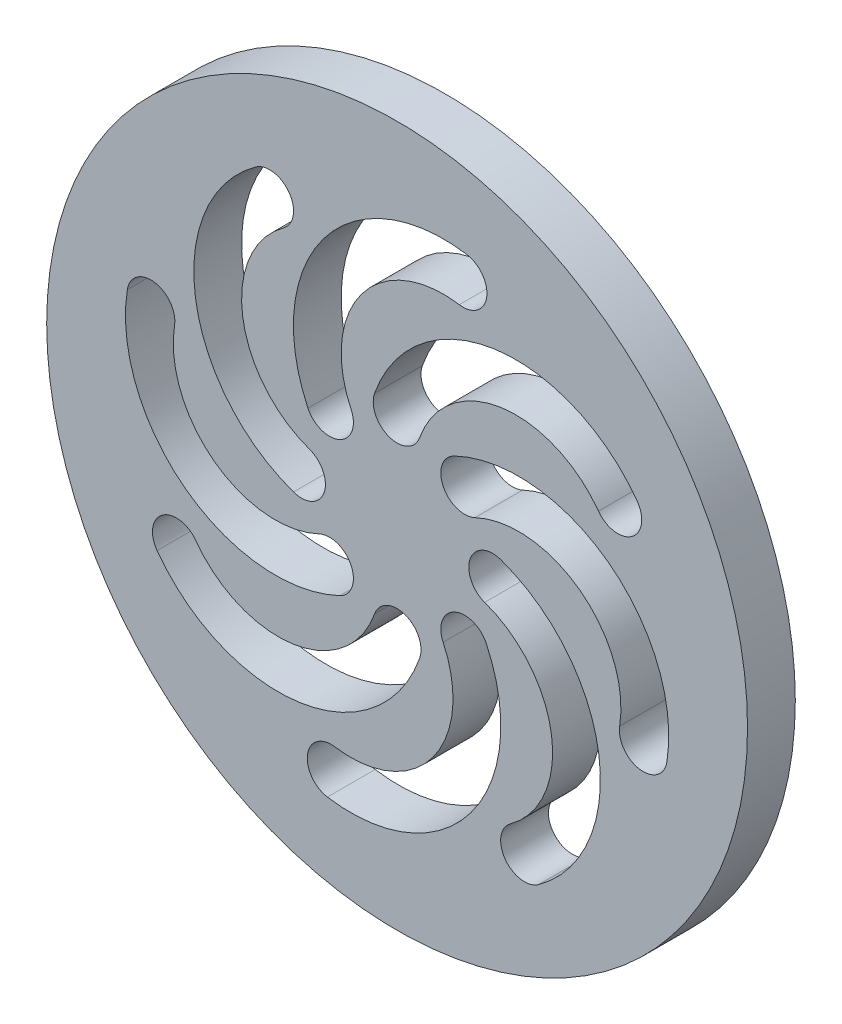
from build123d import *

# Parameters (mm, degrees)
SKETCH1_R           = 34.925
BOSS_EXTRUDE1_DEPTH = 4.7625


with BuildPart() as part:
    # Sketch1 → Boss-Extrude1 (new body)
    with BuildSketch(Plane.XY):
        Circle(SKETCH1_R)
        with BuildLine():
            ThreePointArc((2.243888697, 8.727933453), (-0.797066547, 7.281111303), (-2.243888697, 10.322066547))
            ThreePointArc((-2.243888697, 10.322066547), (9.70011878, 20.108105734), (23.923949148, 14.099068603))
            ThreePointArc((23.923949148, 14.099068603), (23.396113859, 10.773096108), (20.070141364, 11.300931397))
            ThreePointArc((20.070141364, 11.300931397), (10.380475923, 15.394453179), (2.243888697, 8.727933453))
        make_face(mode=Mode.SUBTRACT)
        with BuildLine():
            ThreePointArc((5.712134337, 8.885472165), (21.077597689, 7.359558154), (26.886333692, -6.947239658))
            ThreePointArc((26.886333692, -6.947239658), (24.161280075, -8.92582145), (22.182698283, -6.200767833))
            ThreePointArc((22.182698283, -6.200767833), (18.225627153, 3.545417318), (7.758249844, 4.584912017))
            ThreePointArc((7.758249844, 4.584912017), (4.584912017, 5.712134337), (5.712134337, 8.885472165))
        make_face(mode=Mode.SUBTRACT)
        with BuildLine():
            ThreePointArc((10.322066547, 2.243888697), (20.108105734, -9.70011878), (14.099068603, -23.923949148))
            ThreePointArc((14.099068603, -23.923949148), (10.773096108, -23.396113859), (11.300931397, -20.070141364))
            ThreePointArc((11.300931397, -20.070141364), (15.394453179, -10.380475923), (8.727933453, -2.243888697))
            ThreePointArc((8.727933453, -2.243888697), (7.281111303, 0.797066547), (10.322066547, 2.243888697))
        make_face(mode=Mode.SUBTRACT)
        with BuildLine():
            ThreePointArc((8.885472165, -5.712134337), (7.359558154, -21.077597689), (-6.947239658, -26.886333692))
            ThreePointArc((-6.947239658, -26.886333692), (-8.92582145, -24.161280075), (-6.200767833, -22.182698283))
            ThreePointArc((-6.200767833, -22.182698283), (3.545417318, -18.225627153), (4.584912017, -7.758249844))
            ThreePointArc((4.584912017, -7.758249844), (5.712134337, -4.584912017), (8.885472165, -5.712134337))
        make_face(mode=Mode.SUBTRACT)
        with BuildLine():
            ThreePointArc((2.243888697, -10.322066547), (-9.70011878, -20.108105734), (-23.923949148, -14.099068603))
            ThreePointArc((-23.923949148, -14.099068603), (-23.396113859, -10.773096108), (-20.070141364, -11.300931397))
            ThreePointArc((-20.070141364, -11.300931397), (-10.380475923, -15.394453179), (-2.243888697, -8.727933453))
            ThreePointArc((-2.243888697, -8.727933453), (0.797066547, -7.281111303), (2.243888697, -10.322066547))
        make_face(mode=Mode.SUBTRACT)
        with BuildLine():
            ThreePointArc((-5.712134337, -8.885472165), (-21.077597689, -7.359558154), (-26.886333692, 6.947239658))
            ThreePointArc((-26.886333692, 6.947239658), (-24.161280075, 8.92582145), (-22.182698283, 6.200767833))
            ThreePointArc((-22.182698283, 6.200767833), (-18.225627153, -3.545417318), (-7.758249844, -4.584912017))
            ThreePointArc((-7.758249844, -4.584912017), (-4.584912017, -5.712134337), (-5.712134337, -8.885472165))
        make_face(mode=Mode.SUBTRACT)
        with BuildLine():
            ThreePointArc((-10.322066547, -2.243888697), (-20.108105734, 9.70011878), (-14.099068603, 23.923949148))
            ThreePointArc((-14.099068603, 23.923949148), (-10.773096108, 23.396113859), (-11.300931397, 20.070141364))
            ThreePointArc((-11.300931397, 20.070141364), (-15.394453179, 10.380475923), (-8.727933453, 2.243888697))
            ThreePointArc((-8.727933453, 2.243888697), (-7.281111303, -0.797066547), (-10.322066547, -2.243888697))
        make_face(mode=Mode.SUBTRACT)
        with BuildLine():
            ThreePointArc((-8.885472165, 5.712134337), (-7.359558154, 21.077597689), (6.947239658, 26.886333692))
            ThreePointArc((6.947239658, 26.886333692), (8.92582145, 24.161280075), (6.200767833, 22.182698283))
            ThreePointArc((6.200767833, 22.182698283), (-3.545417318, 18.225627153), (-4.584912017, 7.758249844))
            ThreePointArc((-4.584912017, 7.758249844), (-5.712134337, 4.584912017), (-8.885472165, 5.712134337))
        make_face(mode=Mode.SUBTRACT)
    extrude(amount=BOSS_EXTRUDE1_DEPTH)


solid = part.part
